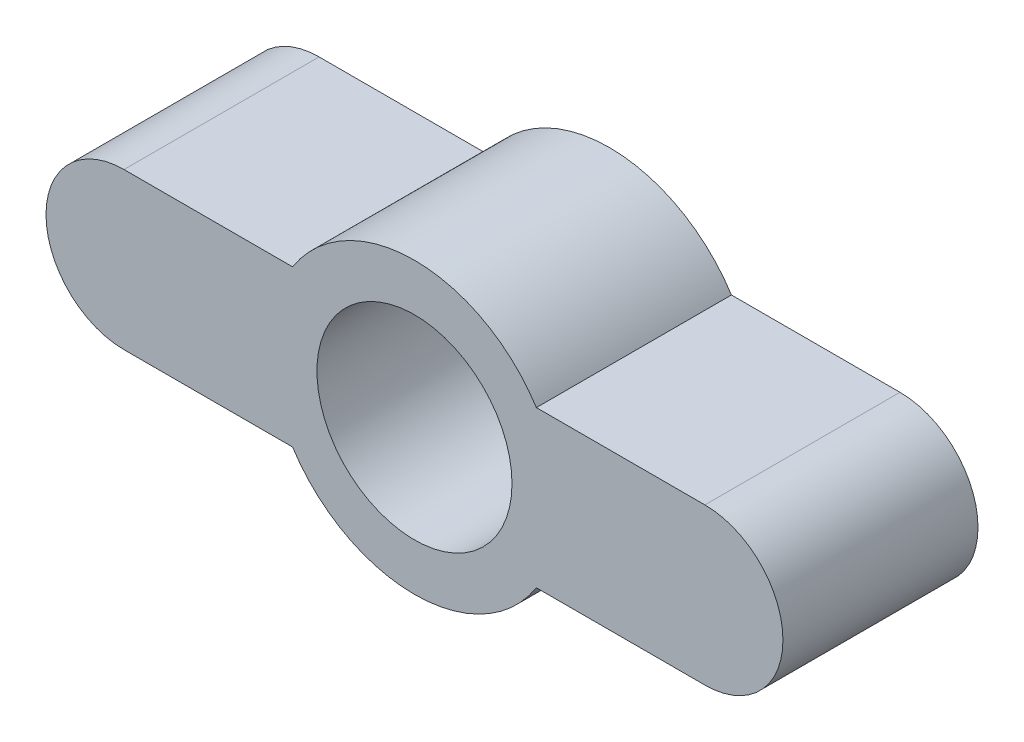
from build123d import *

# Parameters (mm, degrees)
SKETCH1_R           = 2.5
BOSS_EXTRUDE1_DEPTH = 5


with BuildPart() as part:
    # Sketch1 → Boss-Extrude1 (new body)
    with BuildSketch(Plane.XY):
        with BuildLine():
            Line((3.12475599, -2), (7.445, -2))
            ThreePointArc((7.445, -2), (9.445, 0), (7.445, 2))
            Line((7.445, 2), (3.12475599, 2))
            ThreePointArc((3.12475599, 2), (0, 3.71), (-3.12475599, 2))
            Line((-3.12475599, 2), (-7.445, 2))
            ThreePointArc((-7.445, 2), (-9.445, 0), (-7.445, -2))
            Line((-7.445, -2), (-3.12475599, -2))
            ThreePointArc((-3.12475599, -2), (0, -3.71), (3.12475599, -2))
        make_face()
        Circle(SKETCH1_R, mode=Mode.SUBTRACT)
    extrude(amount=BOSS_EXTRUDE1_DEPTH)


solid = part.part
